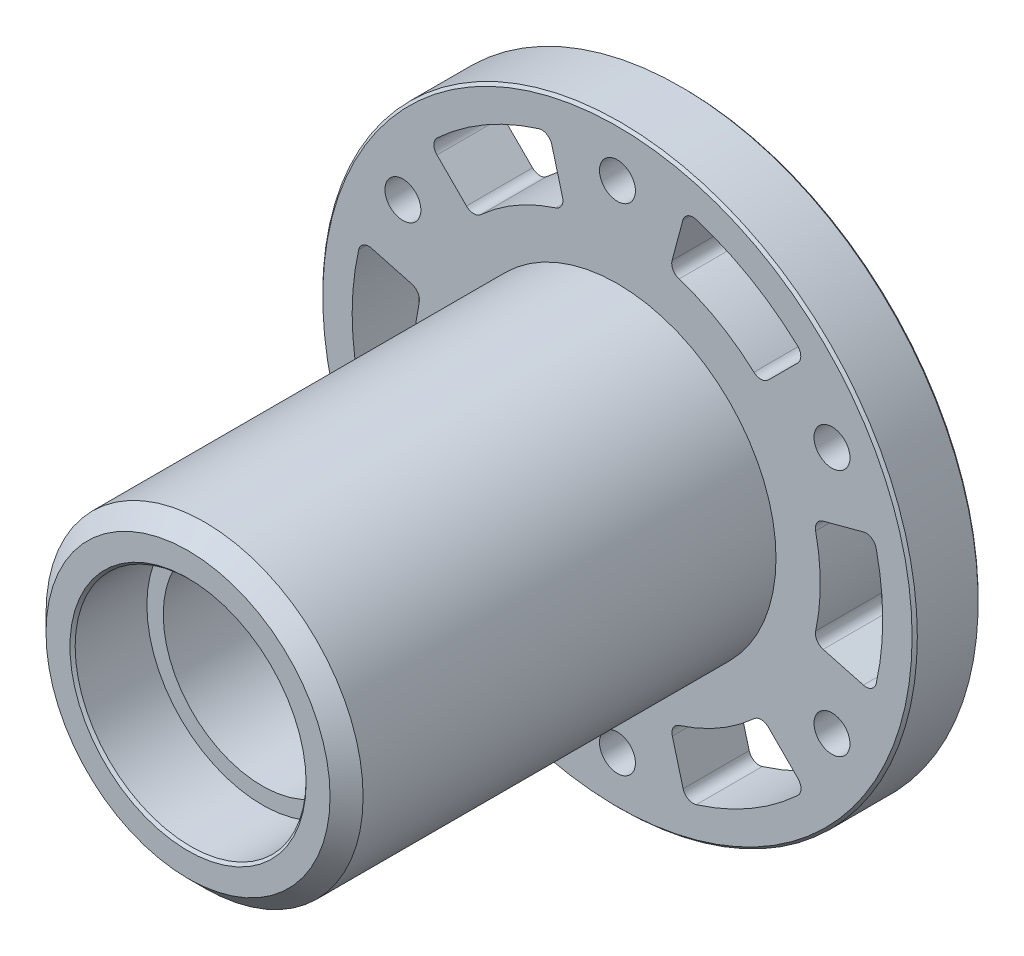
from build123d import *

# Parameters (mm, degrees)
SKETCH1_W                = 28.575
SKETCH1_H                = 6.35
CUT_EXTRUDE1_DEPTH       = 7.35
CUT_EXTRUDE2_DEPTH       = 7.35
CUT_EXTRUDE3_DEPTH       = 7.35
CUT_EXTRUDE4_DEPTH       = 7.35
CUT_EXTRUDE5_DEPTH       = 7.35
CUT_EXTRUDE6_DEPTH       = 7.35
SKETCH8_R                = 15.24
BOSS_EXTRUDE1_DEPTH      = 41.275
M3_CLEARANCE_HOLE1_D     = 3.4544
M3_CLEARANCE_HOLE1_DEPTH = 47.625
CHAMFER1_SIZE            = 0.25
CHAMFER2_SIZE            = 1.5875
FILLET1_R                = 1


with BuildPart() as part:
    # Sketch1 → Revolve1 (revolve)
    with BuildSketch(Plane.XZ):
        with Locations((14.2875, 0)):
            Rectangle(SKETCH1_W, SKETCH1_H)
    revolve(axis=Axis((0, 0, 3.175), (0, 0, -1)))

    # Sketch2 → Cut-Extrude1 (cut, through all)
    with BuildSketch(Plane(origin=(0, 0, -3.175), x_dir=(-1, 0, 0), z_dir=(0, 0, -1))):
        with BuildLine():
            Line((13.824456468, 13.752614419), (18.067108165, 17.995266116))
            ThreePointArc((18.067108165, 17.995266116), (12.760996954, 22.077295051), (6.57534786, 24.637670355))
            Line((6.57534786, 24.637670355), (5.022432582, 18.842111637))
            ThreePointArc((5.022432582, 18.842111637), (9.760996476, 16.88114178), (13.824456468, 13.752614419))
        make_face()
    extrude(amount=-CUT_EXTRUDE1_DEPTH, mode=Mode.SUBTRACT)

    # Sketch3 → Cut-Extrude2 (cut, through all)
    with BuildSketch(Plane(origin=(0, 0, -3.175), x_dir=(-1, 0, 0), z_dir=(0, 0, -1))):
        with BuildLine():
            Line((-4.997885221, 18.848637704), (-6.550803522, 24.644207701))
            ThreePointArc((-6.550803522, 24.644207701), (-12.738999884, 22.089995065), (-18.049174487, 18.013253463))
            Line((-18.049174487, 18.013253463), (-13.806531048, 13.770610024))
            ThreePointArc((-13.806531048, 13.770610024), (-9.738999389, 16.893841804), (-4.997885221, 18.848637704))
        make_face()
    extrude(amount=-CUT_EXTRUDE2_DEPTH, mode=Mode.SUBTRACT)

    # Sketch4 → Cut-Extrude3 (cut, through all)
    with BuildSketch(Plane(origin=(0, 0, -3.175), x_dir=(-1, 0, 0), z_dir=(0, 0, -1))):
        with BuildLine():
            Line((-18.822341689, 5.096023285), (-24.617911686, 6.648941586))
            ThreePointArc((-24.617911686, 6.648941586), (-25.499996837, 0.012700014), (-24.624522347, -6.624416892))
            Line((-24.624522347, -6.624416892), (-18.82896363, -5.071501614))
            ThreePointArc((-18.82896363, -5.071501614), (-19.499995864, 0.012700024), (-18.822341689, 5.096023285))
        make_face()
    extrude(amount=-CUT_EXTRUDE3_DEPTH, mode=Mode.SUBTRACT)

    # Sketch5 → Cut-Extrude4 (cut, through all)
    with BuildSketch(Plane(origin=(0, 0, -3.175), x_dir=(-1, 0, 0), z_dir=(0, 0, -1))):
        with BuildLine():
            Line((-6.57534786, -24.637670355), (-5.022432582, -18.842111637))
            ThreePointArc((-5.022432582, -18.842111637), (-9.760996476, -16.88114178), (-13.824456468, -13.752614419))
            Line((-13.824456468, -13.752614419), (-18.067108165, -17.995266116))
            ThreePointArc((-18.067108165, -17.995266116), (-12.760996954, -22.077295051), (-6.57534786, -24.637670355))
        make_face()
    extrude(amount=-CUT_EXTRUDE4_DEPTH, mode=Mode.SUBTRACT)

    # Sketch6 → Cut-Extrude5 (cut, through all)
    with BuildSketch(Plane(origin=(0, 0, -3.175), x_dir=(-1, 0, 0), z_dir=(0, 0, -1))):
        with BuildLine():
            Line((18.049174487, -18.013253463), (13.806531048, -13.770610024))
            ThreePointArc((13.806531048, -13.770610024), (9.738999389, -16.893841804), (4.997885221, -18.848637704))
            Line((4.997885221, -18.848637704), (6.550803522, -24.644207701))
            ThreePointArc((6.550803522, -24.644207701), (12.738999884, -22.089995065), (18.049174487, -18.013253463))
        make_face()
    extrude(amount=-CUT_EXTRUDE5_DEPTH, mode=Mode.SUBTRACT)

    # Sketch7 → Cut-Extrude6 (cut, through all)
    with BuildSketch(Plane.XY.offset(3.175)):
        with BuildLine():
            Line((-18.82896363, 5.071501614), (-24.624522347, 6.624416892))
            ThreePointArc((-24.624522347, 6.624416892), (-25.499996837, -0.012700014), (-24.617911686, -6.648941586))
            Line((-24.617911686, -6.648941586), (-18.822341689, -5.096023285))
            ThreePointArc((-18.822341689, -5.096023285), (-19.499995864, -0.012700024), (-18.82896363, 5.071501614))
        make_face()
    extrude(amount=-CUT_EXTRUDE6_DEPTH, mode=Mode.SUBTRACT)

    # Sketch8 → Boss-Extrude1 (add)
    with BuildSketch(Plane.XY.offset(3.175)):
        Circle(SKETCH8_R)
    extrude(amount=BOSS_EXTRUDE1_DEPTH)

    # Sketch9 → Cut-Revolve1 (revolve, cut)
    with BuildSketch(Plane.XZ):
        Polygon((11.0998, 44.45), (0, 44.45), (0, -3.175), (11.0998, -3.175), (11.0998, 3.96875), (9.525, 3.96875), (9.525, 37.30625), (11.0998, 37.30625), align=None)
    revolve(axis=Axis((0, 0, 44.45), (0, 0, -1)), mode=Mode.SUBTRACT)

    # M3 Clearance Hole1
    with Locations(Plane(origin=(0, 0, -3.175), x_dir=(-1, 0, 0), z_dir=(0, 0, -1))):
        with Locations((-20.622229928, 11.90625), (-20.622229928, -11.90625), (0, -23.8125), (20.622229928, -11.90625), (20.622229928, 11.90625), (0, 23.8125)):
            Hole(M3_CLEARANCE_HOLE1_D / 2, depth=M3_CLEARANCE_HOLE1_DEPTH)

    # Chamfer1
    chamfer1_edges = [part.edges().sort_by_distance(p)[0] for p in [
        (-11.0998, 0, 44.45),
        (-11.0998, 0, -3.175),
        (-28.575, 0, -3.175),
        (-28.575, 0, 3.175),
    ]]
    chamfer(chamfer1_edges, length=CHAMFER1_SIZE)

    # Chamfer2
    chamfer2_edges = [part.edges().sort_by_distance(p)[0] for p in [
        (-15.24, 0, 44.45),
    ]]
    chamfer(chamfer2_edges, length=CHAMFER2_SIZE)

    # Fillet1
    fillet1_edges = [part.edges().sort_by_distance(p)[0] for p in [
        (-13.824456468, 13.752614419, 0),
        (-5.022432582, 18.842111637, 0),
        (-6.57534786, 24.637670355, 0),
        (-18.067108165, 17.995266116, 0),
        (4.997885221, 18.848637704, 0),
        (13.806531048, 13.770610024, 0),
        (18.049174487, 18.013253463, 0),
        (6.550803522, 24.644207701, 0),
        (18.822341689, 5.096023285, 0),
        (18.82896363, -5.071501614, 0),
        (24.624522347, -6.624416892, 0),
        (24.617911686, 6.648941586, 0),
        (6.57534786, -24.637670355, 0),
        (18.067108165, -17.995266116, 0),
        (13.824456468, -13.752614419, 0),
        (5.022432582, -18.842111637, 0),
        (-18.049174487, -18.013253463, 0),
        (-6.550803522, -24.644207701, 0),
        (-4.997885221, -18.848637704, 0),
        (-13.806531048, -13.770610024, 0),
        (-18.82896363, 5.071501614, 0),
        (-18.822341689, -5.096023285, 0),
        (-24.617911686, -6.648941586, 0),
        (-24.624522347, 6.624416892, 0),
    ]]
    fillet(fillet1_edges, radius=FILLET1_R)


solid = part.part
